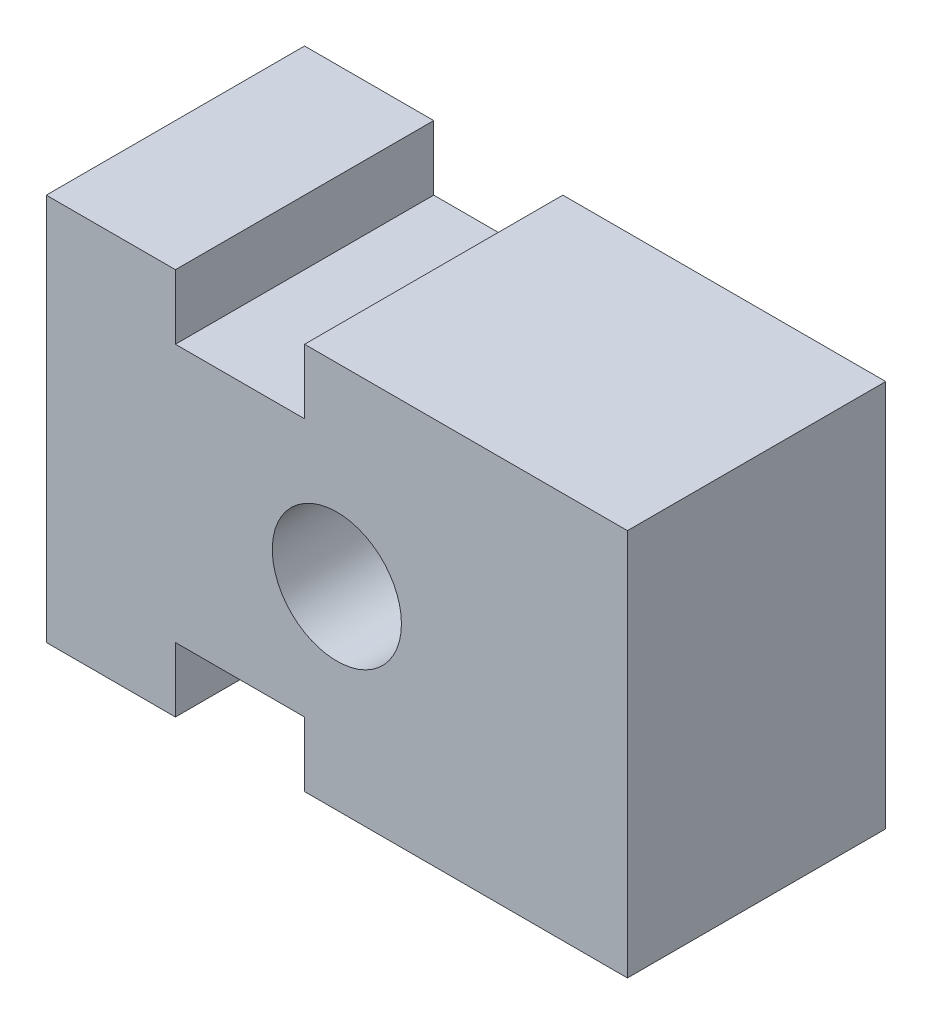
from build123d import *

# Parameters (mm, degrees)
BOSS_EXTRUDE1_DEPTH = 50.8
SKETCH2_R           = 12.7
CUT_EXTRUDE1_DEPTH  = 50.8


with BuildPart() as part:
    # Sketch1 → Boss-Extrude1 (new body)
    with BuildSketch(Plane.XY):
        Polygon((0, 76.2), (0, 0), (25.4, 0), (25.4, 12.7), (50.8, 12.7), (50.8, 0), (114.3, 0), (114.3, 76.2), (50.8, 76.2), (50.8, 63.5), (25.4, 63.5), (25.4, 76.2), align=None)
    extrude(amount=BOSS_EXTRUDE1_DEPTH)

    # Sketch2 → Cut-Extrude1 (cut)
    with BuildSketch(Plane.XY.offset(50.8)):
        with Locations((57.15, 38.1)):
            Circle(SKETCH2_R)
    extrude(amount=-CUT_EXTRUDE1_DEPTH, mode=Mode.SUBTRACT)


solid = part.part
